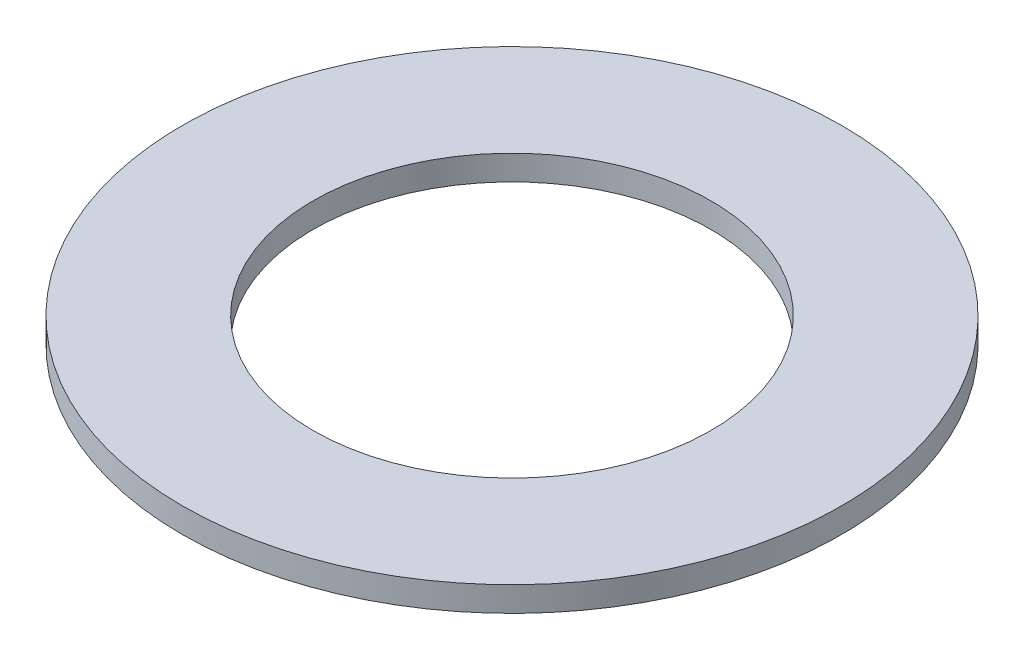
from build123d import *

# Parameters (mm, degrees)
SKETCH_1_R      = 13.25
SKETCH_1_R_2    = 8
EXTRUDE_2_DEPTH = 1


with BuildPart() as part:
    # ｽｹｯﾁ1 → ﾎﾞｽ - 押し出し2 (new body)
    with BuildSketch(Plane(origin=(0, 0, 0), x_dir=(1, 0, 0), z_dir=(0, 1, 0))):
        Circle(SKETCH_1_R)
        Circle(SKETCH_1_R_2, mode=Mode.SUBTRACT)
    extrude(amount=EXTRUDE_2_DEPTH)


solid = part.part
